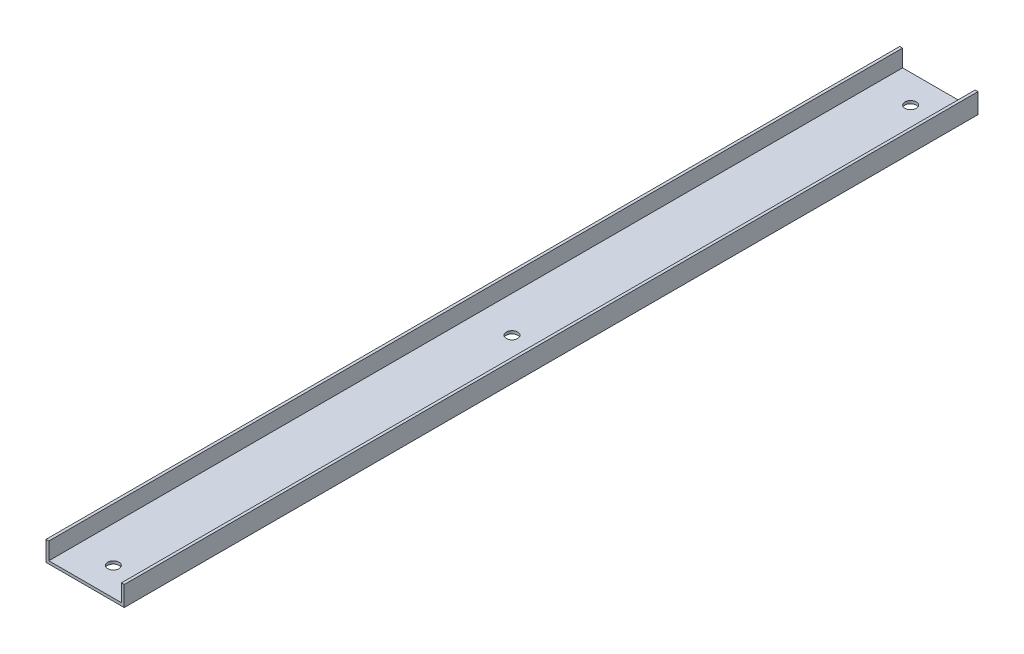
from build123d import *

# Parameters (mm, degrees)
BOSS_EXTRUDE1_DEPTH = 384.175
SKETCH2_R           = 2.54
CUT_EXTRUDE1_DEPTH  = 1.27


with BuildPart() as part:
    # Sketch1 → Boss-Extrude1 (new body)
    with BuildSketch(Plane.XY):
        Polygon((0, 0), (0, -8.9916), (35.2044, -8.9916), (35.2044, 0), (33.9344, 0), (33.9344, -7.7216), (1.27, -7.7216), (1.27, 0), align=None)
    extrude(amount=BOSS_EXTRUDE1_DEPTH)

    # Sketch2 → Cut-Extrude1 (cut)
    with BuildSketch(Plane(origin=(0, -8.9916, 0), x_dir=(-1, 0, 0), z_dir=(0, -1, 0))):
        with Locations((-17.6022, -12.7)):
            Circle(SKETCH2_R)
        with Locations((-17.6022, -192.0875)):
            Circle(SKETCH2_R)
        with Locations((-17.6022, -371.475)):
            Circle(SKETCH2_R)
    extrude(amount=-CUT_EXTRUDE1_DEPTH, mode=Mode.SUBTRACT)


solid = part.part
